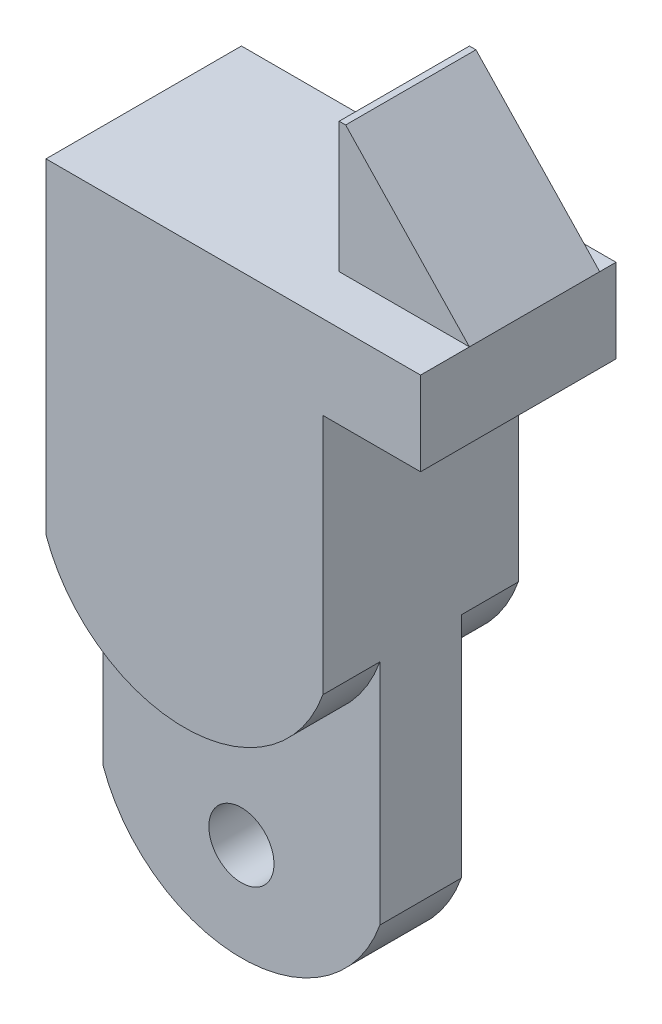
from build123d import *

# Parameters (mm, degrees)
ESQUISSE1_W                  = 11.5
ESQUISSE1_H                  = 20
BOSS_EXTRU_2_DEPTH           = 6
ESQUISSE2_W                  = 3
ESQUISSE2_H                  = 17.429003376
ENL_V_MAT_EXTRU_1_DEPTH      = 6
ENL_V_MAT_EXTRU_2_DEPTH      = 1.75
ENL_V_MAT_EXTRU_4_DEPTH      = 1
ENL_V_MAT_EXTRU_4_DEPTH_BACK = 1.75
ENL_V_MAT_EXTRU_5_DEPTH      = 2.5
ESQUISSE7_R                  = 1
ENL_V_MAT_EXTRU_6_DEPTH      = 2.5
ESQUISSE8_W                  = 4
ESQUISSE8_H                  = 4
BOSS_EXTRU_3_DEPTH           = 4
ENL_V_MAT_EXTRU_8_DEPTH      = 4


with BuildPart() as part:
    # Esquisse1 → Boss.-Extru.2 (new body)
    with BuildSketch(Plane.XY):
        with Locations((5.75, -10)):
            Rectangle(ESQUISSE1_W, ESQUISSE1_H)
    extrude(amount=BOSS_EXTRU_2_DEPTH)

    # Esquisse2 → Enlèv. mat.-Extru.1 (cut)
    with BuildSketch(Plane.XY.offset(6)):
        with Locations((10, -11.285498312)):
            Rectangle(ESQUISSE2_W, ESQUISSE2_H)
    extrude(amount=-ENL_V_MAT_EXTRU_1_DEPTH, mode=Mode.SUBTRACT)

    # Esquisse4 → Enlèv. mat.-Extru.2 (cut)
    with BuildSketch(Plane.XY.offset(6)):
        with BuildLine():
            Line((0, -10), (0, -20))
            Line((0, -20), (8.5, -20))
            Line((8.5, -20), (8.5, -10))
            ThreePointArc((8.5, -10), (4.25, -13), (0, -10))
        make_face()
    extrude(amount=-ENL_V_MAT_EXTRU_2_DEPTH, mode=Mode.SUBTRACT)

    # Esquisse5 → Enlèv. mat.-Extru.4 (cut, two sides)
    with BuildSketch(Plane(origin=(0, 0, 0), x_dir=(-1, 0, 0), z_dir=(0, 0, -1))) as enl_v_mat_extru_4_sk:
        with BuildLine():
            Line((0, -20), (0, -10))
            ThreePointArc((0, -10), (-4.25, -13), (-8.5, -10))
            Line((-8.5, -10), (-8.5, -20))
            Line((-8.5, -20), (0, -20))
        make_face()
    extrude(amount=ENL_V_MAT_EXTRU_4_DEPTH, mode=Mode.SUBTRACT)
    extrude(enl_v_mat_extru_4_sk.sketch, amount=-ENL_V_MAT_EXTRU_4_DEPTH_BACK, mode=Mode.SUBTRACT)

    # Esquisse6 → Enlèv. mat.-Extru.5 (cut)
    with BuildSketch(Plane(origin=(0, 0, 1.75), x_dir=(-1, 0, 0), z_dir=(0, 0, -1))):
        with BuildLine():
            ThreePointArc((-4.25, -20), (-6.851081506, -19.1744488), (-8.5, -17))
            Line((-8.5, -17), (-8.5, -20))
            Line((-8.5, -20), (-4.25, -20))
        make_face()
        with BuildLine():
            ThreePointArc((0, -17), (-1.648918494, -19.1744488), (-4.25, -20))
            Line((-4.25, -20), (0, -20))
            Line((0, -20), (0, -17))
        make_face()
    extrude(amount=-ENL_V_MAT_EXTRU_5_DEPTH, mode=Mode.SUBTRACT)

    # Esquisse7 → Enlèv. mat.-Extru.6 (cut)
    with BuildSketch(Plane(origin=(0, 0, 1.75), x_dir=(-1, 0, 0), z_dir=(0, 0, -1))):
        with Locations((-4.25, -17)):
            Circle(ESQUISSE7_R)
    extrude(amount=-ENL_V_MAT_EXTRU_6_DEPTH, mode=Mode.SUBTRACT)

    # Esquisse8 → Boss.-Extru.3 (add)
    with BuildSketch(Plane(origin=(0, 0, 0), x_dir=(1, 0, 0), z_dir=(0, 1, 0))):
        with Locations((9.5, -2.5)):
            Rectangle(ESQUISSE8_W, ESQUISSE8_H)
    extrude(amount=BOSS_EXTRU_3_DEPTH)

    # Esquisse9 → Enlèv. mat.-Extru.8 (cut)
    with BuildSketch(Plane.XY.offset(4.5)):
        Polygon((11.5, 4), (7.7, 4), (11.5, 0), align=None)
    extrude(amount=-ENL_V_MAT_EXTRU_8_DEPTH, mode=Mode.SUBTRACT)


solid = part.part
